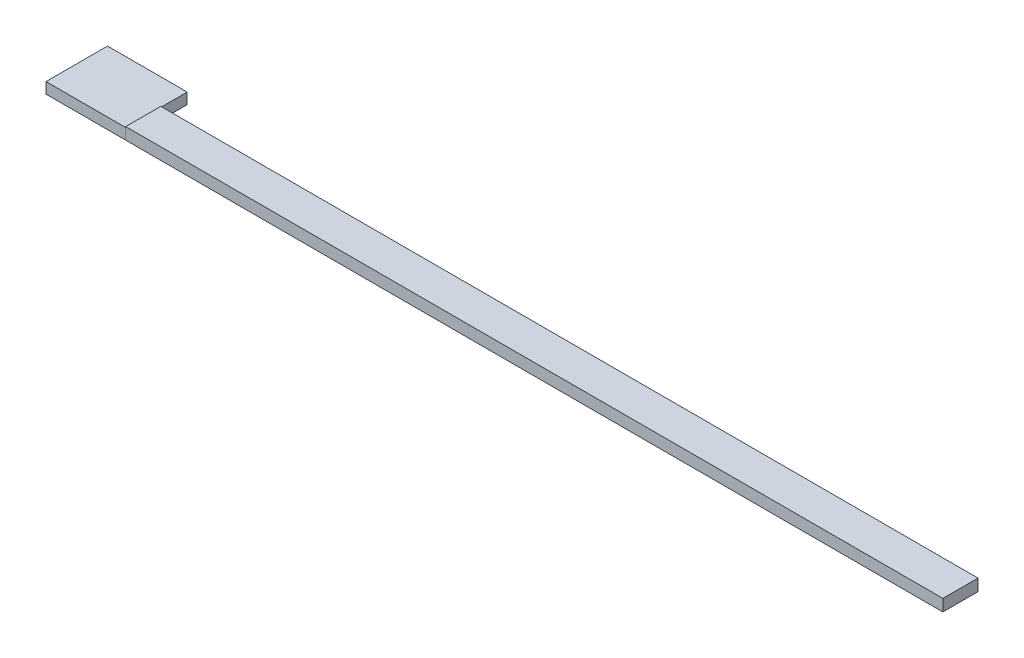
from build123d import *

# Parameters (mm, degrees)
SKIZZE1_W                       = 40
SKIZZE1_H                       = 30.865501512
AUFSATZ_LINEAR_AUSTRAGEN1_DEPTH = 5.47
SKIZZE2_W                       = 410
SKIZZE2_H                       = 17.619447607
AUFSATZ_LINEAR_AUSTRAGEN2_DEPTH = 5.9


with BuildPart() as part:
    # Skizze1 → Aufsatz-Linear austragen1 (new body)
    with BuildSketch(Plane(origin=(0, 0, 0), x_dir=(1, 0, 0), z_dir=(0, 1, 0))):
        with Locations((20, 15.432750756)):
            Rectangle(SKIZZE1_W, SKIZZE1_H)
    extrude(amount=AUFSATZ_LINEAR_AUSTRAGEN1_DEPTH)


with BuildPart() as body_2:
    # Skizze2 → Aufsatz-Linear austragen2 (new body)
    with BuildSketch(Plane(origin=(0, 0, 0), x_dir=(1, 0, 0), z_dir=(0, 1, 0))):
        with Locations((245, 8.809723804)):
            Rectangle(SKIZZE2_W, SKIZZE2_H)
    extrude(amount=AUFSATZ_LINEAR_AUSTRAGEN2_DEPTH)


solid = Compound([part.part, body_2.part])
